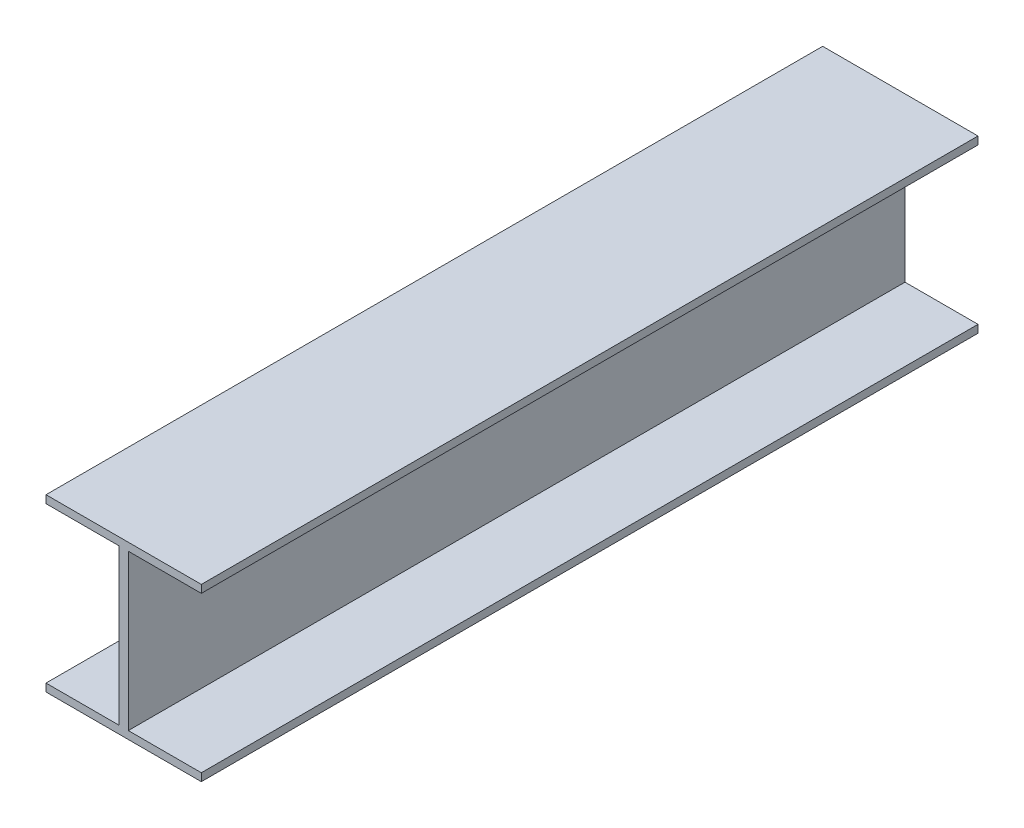
from build123d import *

# Parameters (mm, degrees)
BOSS_EXTRUDE1_DEPTH = 500


with BuildPart() as part:
    # Sketch1 → Boss-Extrude1 (new body)
    with BuildSketch(Plane.XY):
        Polygon((3, -50), (3, 50), (50, 50), (50, 55), (-50, 55), (-50, 50), (-3, 50), (-3, -50), (-50, -50), (-50, -55), (50, -55), (50, -50), align=None)
    extrude(amount=BOSS_EXTRUDE1_DEPTH)


solid = part.part
